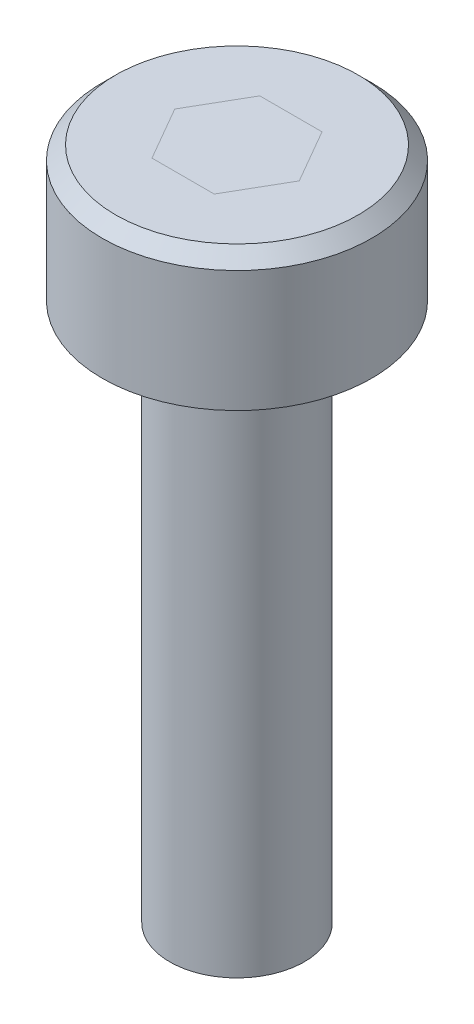
from build123d import *

# Parameters (mm, degrees)
SK_CBORE_R      = 5
BD_CBORE_DEPTH  = 5
SK_THREAD_R     = 2.5
BD_THREAD_DEPTH = 20
CF_CBORE_SIZE   = 0.5


with BuildPart() as part:
    # SK_CBORE → BD_CBORE (new body)
    with BuildSketch(Plane(origin=(0, 0, 0), x_dir=(0, 0, -1), z_dir=(0, 1, 0))):
        Circle(SK_CBORE_R)
    extrude(amount=BD_CBORE_DEPTH)

    # SK_THREAD → BD_THREAD (add)
    with BuildSketch(Plane.XZ):
        Circle(SK_THREAD_R)
    extrude(amount=BD_THREAD_DEPTH)

    # CF_CBORE
    cf_cbore_edges = [part.edges().sort_by_distance(p)[0] for p in [
        (0, 5, 5),
    ]]
    chamfer(cf_cbore_edges, length=CF_CBORE_SIZE)


solid = part.part
